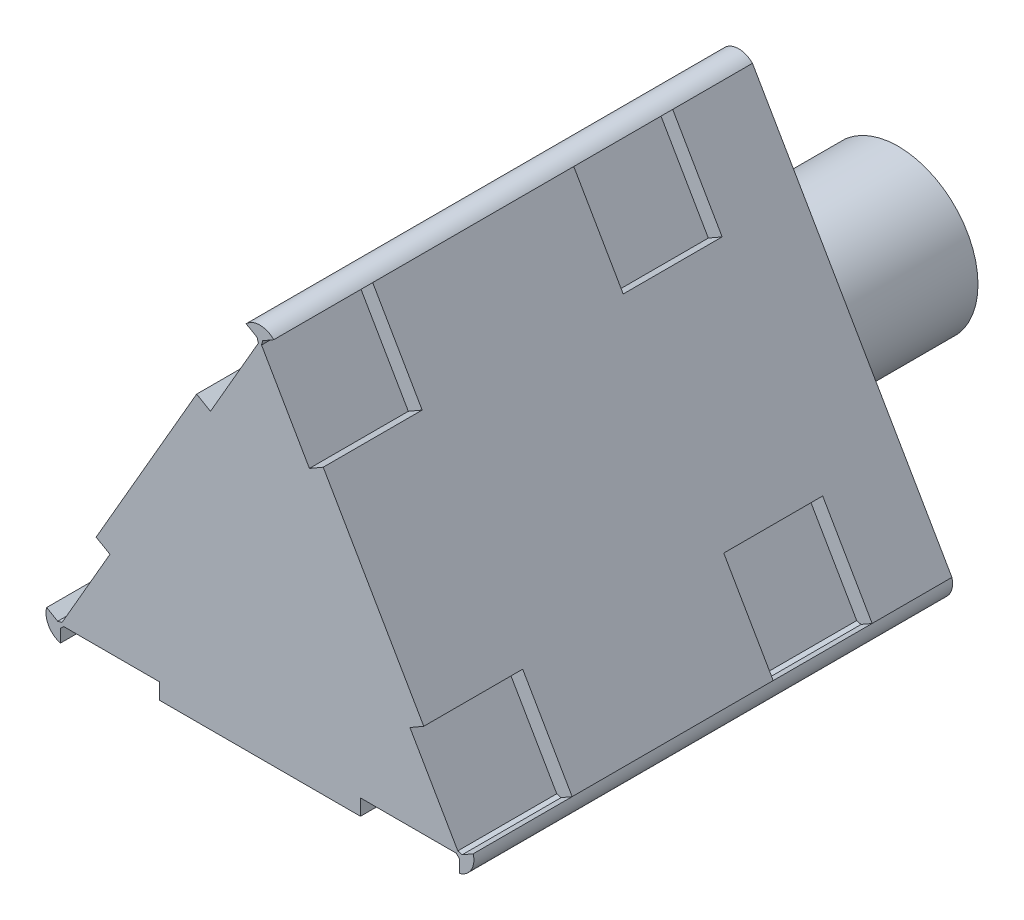
from build123d import *

# Parameters (mm, degrees)
EXTRUDE_1_DEPTH       = 30
EXTRUDE_8_DEPTH       = 30
SKETCH_2_W            = 6.2
SKETCH_2_H            = 6.2
CUT_EXTRUDE_5_DEPTH   = 1
EXTRUDE_9_DEPTH       = 6.2
EXTRUDE_9_DEPTH_BACK  = 23.8
SKETCH_15_W           = 6.2
SKETCH_15_H           = 6.2
CUT_EXTRUDE_10_DEPTH  = 1
EXTRUDE_10_DEPTH      = 6.2
EXTRUDE_10_DEPTH_BACK = 23.8
EXTRUDE_11_DEPTH      = 6.2
EXTRUDE_11_DEPTH_BACK = 23.8
SKETCH_20_W           = 6.2
SKETCH_20_H           = 6.2
CUT_EXTRUDE_11_DEPTH  = 1
EXTRUDE_12_DEPTH      = 6.2
EXTRUDE_12_DEPTH_BACK = 23.8
EXTRUDE_13_DEPTH      = 6.2
EXTRUDE_13_DEPTH_BACK = 23.8
EXTRUDE_14_DEPTH      = 6.2
EXTRUDE_14_DEPTH_BACK = 23.8
SKETCH_25_R           = 5
EXTRUDE_15_DEPTH      = 10


with BuildPart() as part:
    # ｽｹｯﾁ1 → ﾎﾞｽ - 押し出し1 (new body)
    with BuildSketch(Plane.XY):
        Polygon((0, 21.650635095), (-12.5, 0), (12.5, 0), align=None)
    extrude(amount=EXTRUDE_1_DEPTH)

    # ｽｹｯﾁ11 → ﾎﾞｽ - 押し出し8 (add, through all)
    with BuildSketch(Plane(origin=(0, 0, 0), x_dir=(-1, 0, 0), z_dir=(0, 0, -1))):
        with BuildLine():
            Line((0.866025404, 22.150635095), (13.366025404, 0.5))
            ThreePointArc((13.366025404, 0.5), (13.243672874, -0.429359734), (12.5, -1))
            Line((12.5, -1), (-12.5, -1))
            ThreePointArc((-12.5, -1), (-13.243672874, -0.429359734), (-13.366025404, 0.5))
            Line((-13.366025404, 0.5), (-0.866025404, 22.150635095))
            ThreePointArc((-0.866025404, 22.150635095), (0, 22.509354562), (0.866025404, 22.150635095))
        make_face()
        Polygon((0, 21.650635095), (12.5, 0), (-12.5, 0), align=None, mode=Mode.SUBTRACT)
    extrude(amount=-EXTRUDE_8_DEPTH)

    # ｽｹｯﾁ2 → ｶｯﾄ - 押し出し5 (cut)
    with BuildSketch(Plane(origin=(-9.375, 5.412658774, 0), x_dir=(0, 0, 1), z_dir=(-0.866025404, 0.5, 0))):
        with Locations((26.9, -3.15)):
            Rectangle(SKETCH_2_W, SKETCH_2_H)
        with Locations((26.9, 15.65)):
            Rectangle(SKETCH_2_W, SKETCH_2_H)
        with Locations((8.1, -3.15)):
            Rectangle(SKETCH_2_W, SKETCH_2_H)
        with Locations((8.1, 15.65)):
            Rectangle(SKETCH_2_W, SKETCH_2_H)
    extrude(amount=CUT_EXTRUDE_5_DEPTH, mode=Mode.SUBTRACT)

    # ｽｹｯﾁ16 → ﾎﾞｽ - 押し出し9 (add, two sides)
    with BuildSketch(Plane.XY.offset(23.8)) as extrude_9_sk:
        Polygon((-12.4, 0.173205081), (-12.673205081, 0.1), (-12.5, 0), align=None)
    extrude(amount=EXTRUDE_9_DEPTH)
    extrude(extrude_9_sk.sketch, amount=-EXTRUDE_9_DEPTH_BACK)

    # ｽｹｯﾁ15 → ｶｯﾄ - 押し出し10 (cut)
    with BuildSketch(Plane.XZ):
        with Locations((-9.4, 26.9)):
            Rectangle(SKETCH_15_W, SKETCH_15_H)
        with Locations((9.4, 26.9)):
            Rectangle(SKETCH_15_W, SKETCH_15_H)
        with Locations((9.4, 8.1)):
            Rectangle(SKETCH_15_W, SKETCH_15_H)
        with Locations((-9.4, 8.1)):
            Rectangle(SKETCH_15_W, SKETCH_15_H)
    extrude(amount=CUT_EXTRUDE_10_DEPTH, mode=Mode.SUBTRACT)

    # ｽｹｯﾁ18 → ﾎﾞｽ - 押し出し10 (add, two sides)
    with BuildSketch(Plane.XY.offset(23.8)) as extrude_10_sk:
        Polygon((-0.173205081, 21.750635095), (0, 21.650635095), (-0.1, 21.477430014), align=None)
    extrude(amount=EXTRUDE_10_DEPTH)
    extrude(extrude_10_sk.sketch, amount=-EXTRUDE_10_DEPTH_BACK)

    # ｽｹｯﾁ19 → ﾎﾞｽ - 押し出し11 (add, two sides)
    with BuildSketch(Plane.XY.offset(23.8)) as extrude_11_sk:
        Polygon((12.5, 0), (12.3, 0), (12.5, -0.2), align=None)
    extrude(amount=EXTRUDE_11_DEPTH)
    extrude(extrude_11_sk.sketch, amount=-EXTRUDE_11_DEPTH_BACK)

    # ｽｹｯﾁ20 → ｶｯﾄ - 押し出し11 (cut)
    with BuildSketch(Plane(origin=(9.375, 5.412658774, 0), x_dir=(0, 0, -1), z_dir=(0.866025404, 0.5, 0))):
        with Locations((-26.9, -3.15)):
            Rectangle(SKETCH_20_W, SKETCH_20_H)
        with Locations((-26.9, 15.65)):
            Rectangle(SKETCH_20_W, SKETCH_20_H)
        with Locations((-8.1, -3.15)):
            Rectangle(SKETCH_20_W, SKETCH_20_H)
        with Locations((-8.1, 15.65)):
            Rectangle(SKETCH_20_W, SKETCH_20_H)
    extrude(amount=CUT_EXTRUDE_11_DEPTH, mode=Mode.SUBTRACT)

    # ｽｹｯﾁ21 → ﾎﾞｽ - 押し出し12 (add, two sides)
    with BuildSketch(Plane.XY.offset(23.8)) as extrude_12_sk:
        Polygon((0, 21.650635095), (0.1, 21.477430014), (0.173205081, 21.750635095), align=None)
    extrude(amount=EXTRUDE_12_DEPTH)
    extrude(extrude_12_sk.sketch, amount=-EXTRUDE_12_DEPTH_BACK)

    # ｽｹｯﾁ23 → ﾎﾞｽ - 押し出し13 (add, two sides)
    with BuildSketch(Plane.XY.offset(23.8)) as extrude_13_sk:
        Polygon((12.5, 0), (12.673205081, 0.1), (12.4, 0.173205081), align=None)
    extrude(amount=EXTRUDE_13_DEPTH)
    extrude(extrude_13_sk.sketch, amount=-EXTRUDE_13_DEPTH_BACK)

    # ｽｹｯﾁ24 → ﾎﾞｽ - 押し出し14 (add, two sides)
    with BuildSketch(Plane.XY.offset(23.8)) as extrude_14_sk:
        Polygon((-12.5, 0), (-12.3, 0), (-12.5, -0.2), align=None)
    extrude(amount=EXTRUDE_14_DEPTH)
    extrude(extrude_14_sk.sketch, amount=-EXTRUDE_14_DEPTH_BACK)

    # ｽｹｯﾁ25 → ﾎﾞｽ - 押し出し15 (add)
    with BuildSketch(Plane(origin=(0, 0, 0), x_dir=(-1, 0, 0), z_dir=(0, 0, -1))):
        with Locations((0, 7.216878365)):
            Circle(SKETCH_25_R)
    extrude(amount=EXTRUDE_15_DEPTH)


solid = part.part
